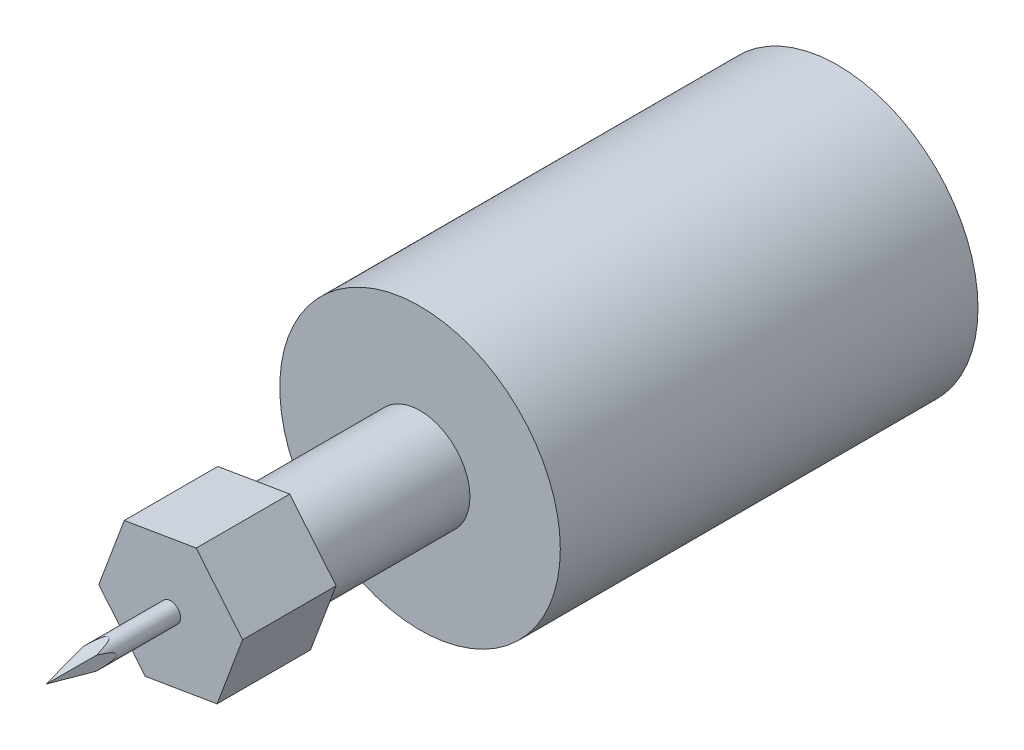
from build123d import *

# Parameters (mm, degrees)
SKETCH1_R                      = 22.5
BOSS_EXTRUDE1_DEPTH            = 67
SKETCH2_R                      = 8
BOSS_EXTRUDE2_DEPTH            = 40
BOSS_EXTRUDE3_DEPTH            = 15
SKETCH4_R                      = 1.5875
BOSS_EXTRUDE4_DEPTH            = 20
CUT_EXTRUDE1_REACH             = 24.5
CUT_EXTRUDE1_DIRECTION_2_REACH = 24.5
CUT_EXTRUDE2_REACH             = 24.5
CUT_EXTRUDE2_DIRECTION_2_REACH = 24.5
SKETCH7_R                      = 17.895926968
BOSS_EXTRUDE5_DEPTH            = 2


with BuildPart() as part:
    # Sketch1 → Boss-Extrude1 (new body)
    with BuildSketch(Plane.XY):
        Circle(SKETCH1_R)
    extrude(amount=BOSS_EXTRUDE1_DEPTH)

    # Sketch2 → Boss-Extrude2 (add)
    with BuildSketch(Plane.XY.offset(67)):
        Circle(SKETCH2_R)
    extrude(amount=BOSS_EXTRUDE2_DEPTH)

    # Sketch3 → Boss-Extrude3 (add)
    with BuildSketch(Plane.XY.offset(107)):
        Polygon((11.534146379, 1.930154149), (4.095510664, 10.95394085), (-7.438635716, 9.023786701), (-11.534146379, -1.930154149), (-4.095510664, -10.95394085), (7.438635716, -9.023786701), align=None)
    extrude(amount=-BOSS_EXTRUDE3_DEPTH)

    # Sketch4 → Boss-Extrude4 (add)
    with BuildSketch(Plane.XY.offset(107)):
        Circle(SKETCH4_R)
    extrude(amount=BOSS_EXTRUDE4_DEPTH)

    # Sketch5 → Cut-Extrude1 (cut, up to next)
    with BuildSketch(Plane(origin=(0, 0, 0), x_dir=(1, 0, 0), z_dir=(0, 1, 0)), mode=Mode.PRIVATE) as cut_extrude1_sk1:
        Polygon((-1.5875, -127), (0, -127), (-1.5875, -117), align=None)
    cut_extrude1_tool1 = extrude(cut_extrude1_sk1.sketch, amount=-CUT_EXTRUDE1_REACH, mode=Mode.PRIVATE) & part.part
    add(cut_extrude1_tool1.solids().sort_by_distance((-1.058333, 0, 123.666667))[0], mode=Mode.SUBTRACT)
    # Sketch5 → Cut-Extrude1 (cut, up to next)
    with BuildSketch(Plane(origin=(0, 0, 0), x_dir=(1, 0, 0), z_dir=(0, 1, 0)), mode=Mode.PRIVATE) as cut_extrude1_sk2:
        Polygon((1.630697713, -117), (0, -127), (1.5875, -127), align=None)
    cut_extrude1_tool2 = extrude(cut_extrude1_sk2.sketch, amount=-CUT_EXTRUDE1_REACH, mode=Mode.PRIVATE) & part.part
    add(cut_extrude1_tool2.solids().sort_by_distance((1.072733, 0, 123.666667))[0], mode=Mode.SUBTRACT)

    # Sketch5 → Cut-Extrude1 direction 2 (cut, up to next)
    with BuildSketch(Plane(origin=(0, 0, 0), x_dir=(1, 0, 0), z_dir=(0, 1, 0)), mode=Mode.PRIVATE) as cut_extrude1_direction_2_sk1:
        Polygon((-1.5875, -127), (0, -127), (-1.5875, -117), align=None)
    cut_extrude1_direction_2_tool1 = extrude(cut_extrude1_direction_2_sk1.sketch, amount=CUT_EXTRUDE1_DIRECTION_2_REACH, mode=Mode.PRIVATE) & part.part
    add(cut_extrude1_direction_2_tool1.solids().sort_by_distance((-1.058333, 0, 123.666667))[0], mode=Mode.SUBTRACT)
    # Sketch5 → Cut-Extrude1 direction 2 (cut, up to next)
    with BuildSketch(Plane(origin=(0, 0, 0), x_dir=(1, 0, 0), z_dir=(0, 1, 0)), mode=Mode.PRIVATE) as cut_extrude1_direction_2_sk2:
        Polygon((1.630697713, -117), (0, -127), (1.5875, -127), align=None)
    cut_extrude1_direction_2_tool2 = extrude(cut_extrude1_direction_2_sk2.sketch, amount=CUT_EXTRUDE1_DIRECTION_2_REACH, mode=Mode.PRIVATE) & part.part
    add(cut_extrude1_direction_2_tool2.solids().sort_by_distance((1.072733, 0, 123.666667))[0], mode=Mode.SUBTRACT)

    # Sketch6 → Cut-Extrude2 (cut, up to next)
    with BuildSketch(Plane(origin=(0, 0, 0), x_dir=(0, 0, -1), z_dir=(1, 0, 0)), mode=Mode.PRIVATE) as cut_extrude2_sk1:
        Polygon((-127, -1.5875), (-117, -1.5875), (-127, 0), align=None)
    cut_extrude2_tool1 = extrude(cut_extrude2_sk1.sketch, amount=-CUT_EXTRUDE2_REACH, mode=Mode.PRIVATE) & part.part
    add(cut_extrude2_tool1.solids().sort_by_distance((0, -1.058333, 123.666667))[0], mode=Mode.SUBTRACT)
    # Sketch6 → Cut-Extrude2 (cut, up to next)
    with BuildSketch(Plane(origin=(0, 0, 0), x_dir=(0, 0, -1), z_dir=(1, 0, 0)), mode=Mode.PRIVATE) as cut_extrude2_sk2:
        Polygon((-127, 0), (-117, 1.5875), (-127, 1.5875), align=None)
    cut_extrude2_tool2 = extrude(cut_extrude2_sk2.sketch, amount=-CUT_EXTRUDE2_REACH, mode=Mode.PRIVATE) & part.part
    add(cut_extrude2_tool2.solids().sort_by_distance((0, 1.058333, 123.666667))[0], mode=Mode.SUBTRACT)

    # Sketch6 → Cut-Extrude2 direction 2 (cut, up to next)
    with BuildSketch(Plane(origin=(0, 0, 0), x_dir=(0, 0, -1), z_dir=(1, 0, 0)), mode=Mode.PRIVATE) as cut_extrude2_direction_2_sk1:
        Polygon((-127, -1.5875), (-117, -1.5875), (-127, 0), align=None)
    cut_extrude2_direction_2_tool1 = extrude(cut_extrude2_direction_2_sk1.sketch, amount=CUT_EXTRUDE2_DIRECTION_2_REACH, mode=Mode.PRIVATE) & part.part
    add(cut_extrude2_direction_2_tool1.solids().sort_by_distance((0, -1.058333, 123.666667))[0], mode=Mode.SUBTRACT)
    # Sketch6 → Cut-Extrude2 direction 2 (cut, up to next)
    with BuildSketch(Plane(origin=(0, 0, 0), x_dir=(0, 0, -1), z_dir=(1, 0, 0)), mode=Mode.PRIVATE) as cut_extrude2_direction_2_sk2:
        Polygon((-127, 0), (-117, 1.5875), (-127, 1.5875), align=None)
    cut_extrude2_direction_2_tool2 = extrude(cut_extrude2_direction_2_sk2.sketch, amount=CUT_EXTRUDE2_DIRECTION_2_REACH, mode=Mode.PRIVATE) & part.part
    add(cut_extrude2_direction_2_tool2.solids().sort_by_distance((0, 1.058333, 123.666667))[0], mode=Mode.SUBTRACT)

    # Sketch7 → Boss-Extrude5 (add)
    with BuildSketch(Plane(origin=(0, 0, 0), x_dir=(-1, 0, 0), z_dir=(0, 0, -1))):
        Circle(SKETCH7_R)
    extrude(amount=BOSS_EXTRUDE5_DEPTH)


solid = part.part
